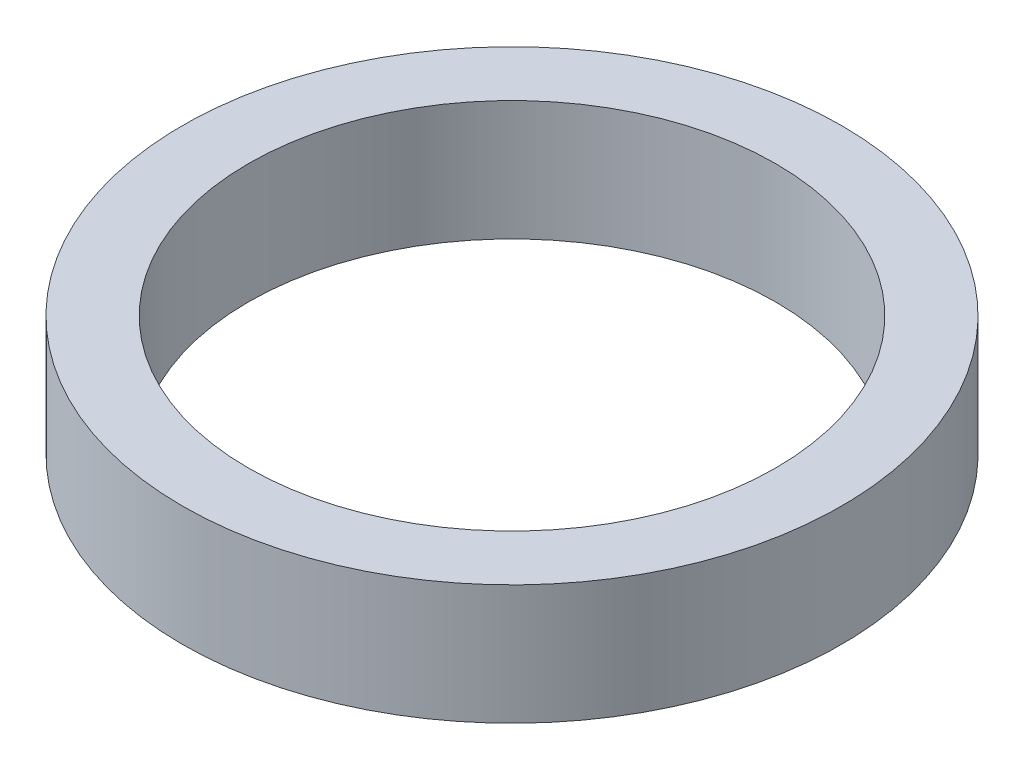
from build123d import *

# Parameters (mm, degrees)
BOSS_EXTRUDE1_DEPTH      = 10
BOSS_EXTRUDE1_DEPTH_BACK = 10
SKETCH1_R                = 55
SKETCH1_R_2              = 44


with BuildPart() as part:
    # Sketch1 → Boss-Extrude1 (new, two sides: drawn at the far end of the back side and taken through both)
    with BuildSketch(Plane(origin=(0, 0, 0), x_dir=(1, 0, 0), z_dir=(0, 1, 0)).offset(-BOSS_EXTRUDE1_DEPTH_BACK)):
        Circle(SKETCH1_R)
        Circle(SKETCH1_R_2, mode=Mode.SUBTRACT)
    extrude(amount=BOSS_EXTRUDE1_DEPTH + BOSS_EXTRUDE1_DEPTH_BACK)


solid = part.part
